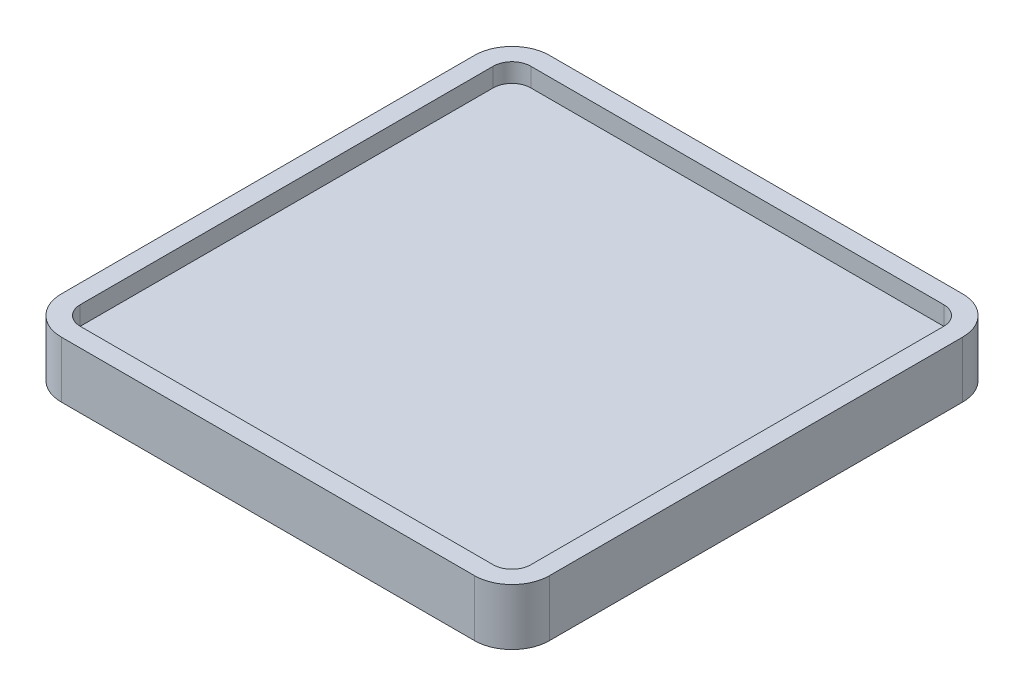
from build123d import *

# Parameters (mm, degrees)
BOSS_EXTRUDE1_DEPTH = 1
BOSS_EXTRUDE2_DEPTH = 2


with BuildPart() as part:
    # Sketch1 → Boss-Extrude1 (new body)
    with BuildSketch(Plane(origin=(0, 0, 0), x_dir=(1, 0, 0), z_dir=(0, 1, 0))):
        with BuildLine():
            Line((-13, 11), (-13, -11))
            ThreePointArc((-13, -11), (-12.414213562, -12.414213562), (-11, -13))
            Line((-11, -13), (11, -13))
            ThreePointArc((11, -13), (12.414213562, -12.414213562), (13, -11))
            Line((13, -11), (13, 11))
            ThreePointArc((13, 11), (12.414213562, 12.414213562), (11, 13))
            Line((11, 13), (-11, 13))
            ThreePointArc((-11, 13), (-12.414213562, 12.414213562), (-13, 11))
        make_face()
        with BuildLine():
            Line((-11, 12), (11, 12))
            ThreePointArc((11, 12), (11.707106781, 11.707106781), (12, 11))
            Line((12, 11), (12, -11))
            ThreePointArc((12, -11), (11.707106781, -11.707106781), (11, -12))
            Line((11, -12), (-11, -12))
            ThreePointArc((-11, -12), (-11.707106781, -11.707106781), (-12, -11))
            Line((-12, -11), (-12, 11))
            ThreePointArc((-12, 11), (-11.707106781, 11.707106781), (-11, 12))
        make_face(mode=Mode.SUBTRACT)
    extrude(amount=BOSS_EXTRUDE1_DEPTH)

    # Sketch2 → Boss-Extrude2 (add)
    with BuildSketch(Plane.XZ):
        with BuildLine():
            Line((-11, -13), (11, -13))
            ThreePointArc((11, -13), (12.414213562, -12.414213562), (13, -11))
            Line((13, -11), (13, 11))
            ThreePointArc((13, 11), (12.414213562, 12.414213562), (11, 13))
            Line((11, 13), (-11, 13))
            ThreePointArc((-11, 13), (-12.414213562, 12.414213562), (-13, 11))
            Line((-13, 11), (-13, -11))
            ThreePointArc((-13, -11), (-12.414213562, -12.414213562), (-11, -13))
        make_face()
    extrude(amount=BOSS_EXTRUDE2_DEPTH)


solid = part.part
